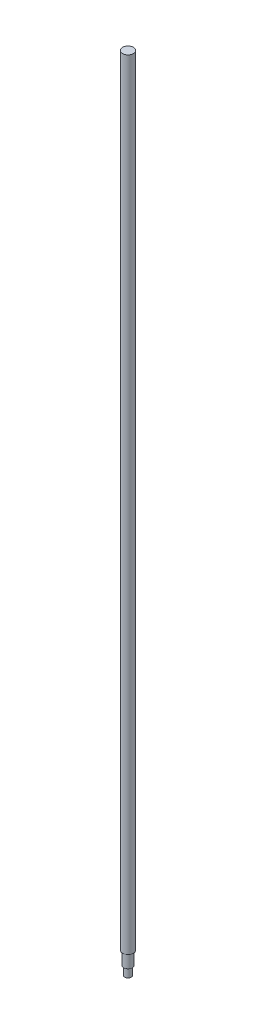
from build123d import *

# Parameters (mm, degrees)
SKETCH1_R           = 7.5
BOSS_EXTRUDE1_DEPTH = 1070
SKETCH_1_R          = 6
EXTRUDE_1_DEPTH     = 18
SKETCH_2_R          = 4.5
EXTRUDE_2_DEPTH     = 12


with BuildPart() as part:
    # Sketch1 → Boss-Extrude1 (new body)
    with BuildSketch(Plane(origin=(0, 0, 0), x_dir=(1, 0, 0), z_dir=(0, 1, 0))):
        Circle(SKETCH1_R)
    extrude(amount=BOSS_EXTRUDE1_DEPTH)

    # Эскиз1 → Бобышка-Вытянуть1 (add)
    with BuildSketch(Plane.XZ):
        Circle(SKETCH_1_R)
    extrude(amount=EXTRUDE_1_DEPTH)

    # Эскиз2 → Бобышка-Вытянуть2 (add)
    with BuildSketch(Plane.XZ.offset(18)):
        Circle(SKETCH_2_R)
    extrude(amount=EXTRUDE_2_DEPTH)


solid = part.part
